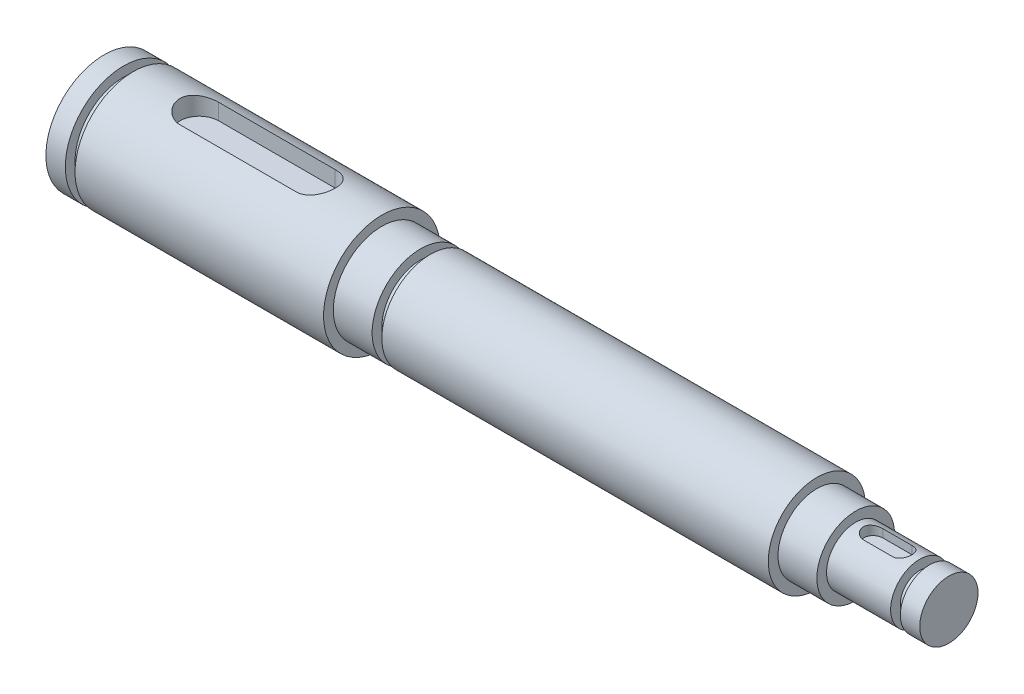
from build123d import *

# Parameters (mm, degrees)
CUT_EXTRUDE1_DEPTH = 3.175
CUT_EXTRUDE2_DEPTH = 1.5875


with BuildPart() as part:
    # Sketch2 → Revolve1 (revolve)
    with BuildSketch(Plane.XY):
        Polygon((0, 0), (138.1125, 0), (138.1125, 4.7625), (134.9375, 4.7625), (134.9375, 3.175), (133.35, 3.175), (133.35, 4.7625), (122.8725, 4.7625), (122.8725, 6.35), (116.5225, 6.35), (116.5225, 7.9375), (53.34, 7.9375), (53.34, 6.35), (51.7525, 6.35), (51.7525, 7.9375), (45.4025, 7.9375), (45.4025, 9.525), (4.7625, 9.525), (4.7625, 7.9375), (3.175, 7.9375), (3.175, 9.525), (0, 9.525), align=None)
    revolve(axis=Axis((0, 0, 0), (-1, 0, 0)))

    # Sketch3 → Cut-Extrude1 (cut)
    with BuildSketch(Plane(origin=(0, 9.525, 0), x_dir=(1, 0, 0), z_dir=(0, 1, 0))):
        with BuildLine():
            Line((15.5575, 3.175), (34.6075, 3.175))
            ThreePointArc((34.6075, 3.175), (37.7825, 0), (34.6075, -3.175))
            Line((34.6075, -3.175), (15.5575, -3.175))
            ThreePointArc((15.5575, -3.175), (12.3825, 0), (15.5575, 3.175))
        make_face()
    extrude(amount=-CUT_EXTRUDE1_DEPTH, mode=Mode.SUBTRACT)

    # Sketch4 → Cut-Extrude2 (cut)
    with BuildSketch(Plane(origin=(0, 4.7625, 0), x_dir=(1, 0, 0), z_dir=(0, 1, 0))):
        with BuildLine():
            Line((125.73, 1.5875), (130.4925, 1.5875))
            ThreePointArc((130.4925, 1.5875), (132.08, 0), (130.4925, -1.5875))
            Line((130.4925, -1.5875), (125.73, -1.5875))
            ThreePointArc((125.73, -1.5875), (124.1425, 0), (125.73, 1.5875))
        make_face()
    extrude(amount=-CUT_EXTRUDE2_DEPTH, mode=Mode.SUBTRACT)


solid = part.part
